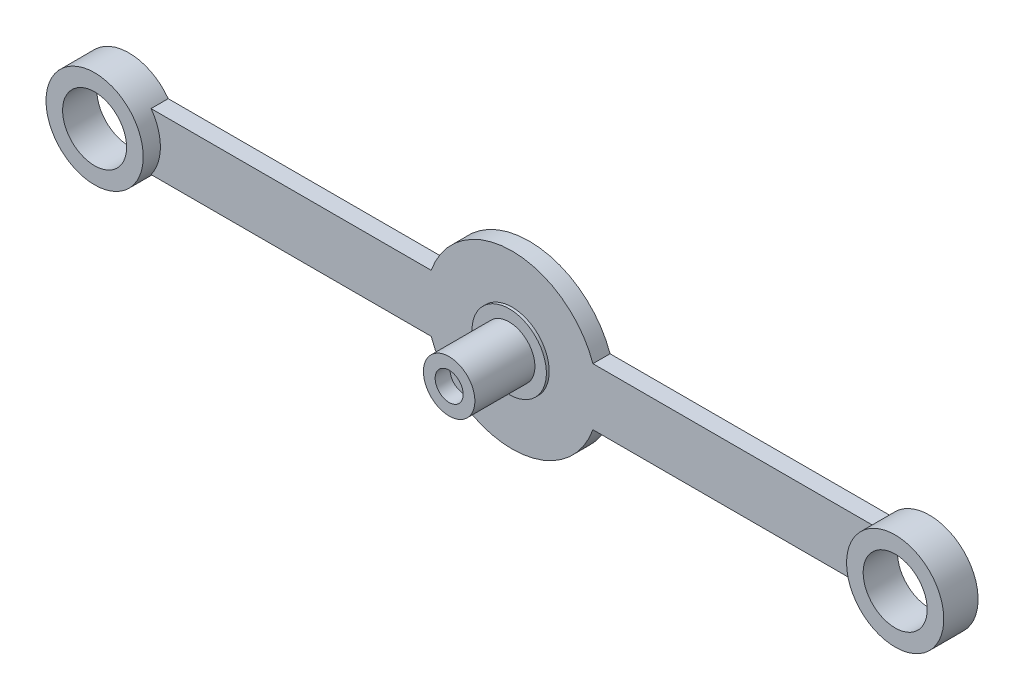
from build123d import *

# Parameters (mm, degrees)
SKETCH1_R               = 4.5
BOSS_EXTRUDE1_DEPTH     = 11
SKETCH2_R               = 5.6
BOSS_EXTRUDE2_DEPTH     = 3
SKETCH3_R               = 6.5
BOSS_EXTRUDE3_DEPTH     = 0.5
SKETCH4_R               = 8.5
SKETCH4_R_2             = 5.6
BOSS_EXTRUDE4_DEPTH     = 3
CUT_EXTRUDE1_START      = 11
SKETCH5_R               = 2.45
CUT_EXTRUDE1_DEPTH      = 2.6
SKETCH7_R               = 1.2
CUT_EXTRUDE3_DEPTH      = 12
CUT_EXTRUDE3_DEPTH_BACK = 4
CUT_EXTRUDE4_START      = -3
SKETCH8_R               = 2.7
CUT_EXTRUDE4_DEPTH      = 8.9


with BuildPart() as part:
    # Sketch1 → Boss-Extrude1 (new body)
    with BuildSketch(Plane.XY):
        Circle(SKETCH1_R)
    extrude(amount=BOSS_EXTRUDE1_DEPTH)

    # Sketch2 → Boss-Extrude2 (add)
    with BuildSketch(Plane.XY):
        with BuildLine():
            Line((14.142135624, 5), (63.126136458, 5))
            ThreePointArc((63.126136458, 5), (78.5, 0), (63.126136458, -5))
            Line((63.126136458, -5), (14.142135624, -5))
            ThreePointArc((14.142135624, -5), (0, -15), (-14.142135624, -5))
            Line((-14.142135624, -5), (-63.126136458, -5))
            ThreePointArc((-63.126136458, -5), (-78.5, 0), (-63.126136458, 5))
            Line((-63.126136458, 5), (-14.142135624, 5))
            ThreePointArc((-14.142135624, 5), (0, 15), (14.142135624, 5))
        make_face()
        with Locations((70, 0)):
            Circle(SKETCH2_R, mode=Mode.SUBTRACT)
        with Locations((-70, 0)):
            Circle(SKETCH2_R, mode=Mode.SUBTRACT)
    extrude(amount=-BOSS_EXTRUDE2_DEPTH)

    # Sketch3 → Boss-Extrude3 (add)
    with BuildSketch(Plane.XY):
        Circle(SKETCH3_R)
    extrude(amount=BOSS_EXTRUDE3_DEPTH)

    # Sketch4 → Boss-Extrude4 (add)
    with BuildSketch(Plane.XY):
        with Locations((-70, 0)):
            Circle(SKETCH4_R)
        with Locations((-70, 0)):
            Circle(SKETCH4_R_2, mode=Mode.SUBTRACT)
        with Locations((70, 0)):
            Circle(SKETCH4_R)
        with Locations((70, 0)):
            Circle(SKETCH4_R_2, mode=Mode.SUBTRACT)
    extrude(amount=BOSS_EXTRUDE4_DEPTH)

    # Sketch5 → Cut-Extrude1 (cut)
    with BuildSketch(Plane.XY.offset(CUT_EXTRUDE1_START)):
        Circle(SKETCH5_R)
    extrude(amount=-CUT_EXTRUDE1_DEPTH, mode=Mode.SUBTRACT)

    # Sketch7 → Cut-Extrude3 (cut, two sides)
    with BuildSketch(Plane.XY) as cut_extrude3_sk:
        Circle(SKETCH7_R)
    extrude(amount=CUT_EXTRUDE3_DEPTH, mode=Mode.SUBTRACT)
    extrude(cut_extrude3_sk.sketch, amount=-CUT_EXTRUDE3_DEPTH_BACK, mode=Mode.SUBTRACT)

    # Sketch8 → Cut-Extrude4 (cut)
    with BuildSketch(Plane.XY.offset(CUT_EXTRUDE4_START)):
        Circle(SKETCH8_R)
    extrude(amount=CUT_EXTRUDE4_DEPTH, mode=Mode.SUBTRACT)


solid = part.part
